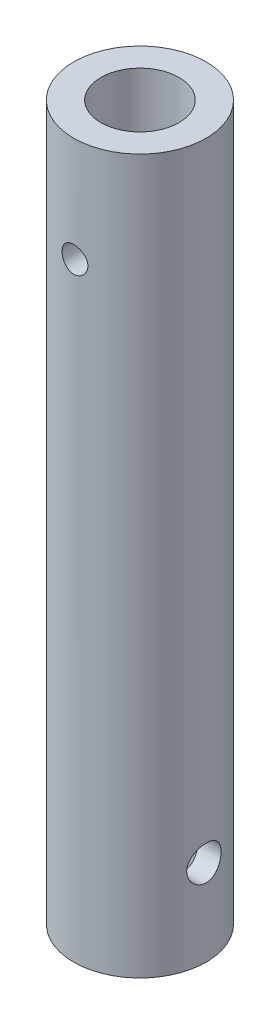
from build123d import *

# Parameters (mm, degrees)
SKETCH1_R               = 9.779
SKETCH1_R_2             = 5.7785
BOSS_EXTRUDE1_DEPTH     = 105.41
SKETCH2_R               = 1.905
CUT_EXTRUDE1_DEPTH      = 10.779
CUT_EXTRUDE1_DEPTH_BACK = 10.779
SKETCH3_R               = 2.54
CUT_EXTRUDE2_DEPTH      = 10.7790001
CUT_EXTRUDE2_DEPTH_BACK = 10.7790001
SKETCH4_R               = 6.604
CUT_EXTRUDE3_DEPTH      = 77.216


with BuildPart() as part:
    # Sketch1 → Boss-Extrude1 (new body)
    with BuildSketch(Plane(origin=(0, 0, 0), x_dir=(1, 0, 0), z_dir=(0, 1, 0))):
        Circle(SKETCH1_R)
        Circle(SKETCH1_R_2, mode=Mode.SUBTRACT)
    extrude(amount=BOSS_EXTRUDE1_DEPTH)

    # Sketch2 → Cut-Extrude1 (cut, two sides)
    with BuildSketch(Plane.XY) as cut_extrude1_sk:
        with Locations((0, 89.916)):
            Circle(SKETCH2_R)
    extrude(amount=CUT_EXTRUDE1_DEPTH, mode=Mode.SUBTRACT)
    extrude(cut_extrude1_sk.sketch, amount=-CUT_EXTRUDE1_DEPTH_BACK, mode=Mode.SUBTRACT)

    # Sketch3 → Cut-Extrude2 (cut, two sides)
    with BuildSketch(Plane(origin=(0, 0, 0), x_dir=(0, 0, -1), z_dir=(1, 0, 0))) as cut_extrude2_sk:
        with Locations((0, 12.7)):
            Circle(SKETCH3_R)
    extrude(amount=CUT_EXTRUDE2_DEPTH, mode=Mode.SUBTRACT)
    extrude(cut_extrude2_sk.sketch, amount=-CUT_EXTRUDE2_DEPTH_BACK, mode=Mode.SUBTRACT)

    # Sketch4 → Cut-Extrude3 (cut)
    with BuildSketch(Plane.XZ):
        Circle(SKETCH4_R)
    extrude(amount=-CUT_EXTRUDE3_DEPTH, mode=Mode.SUBTRACT)


solid = part.part
